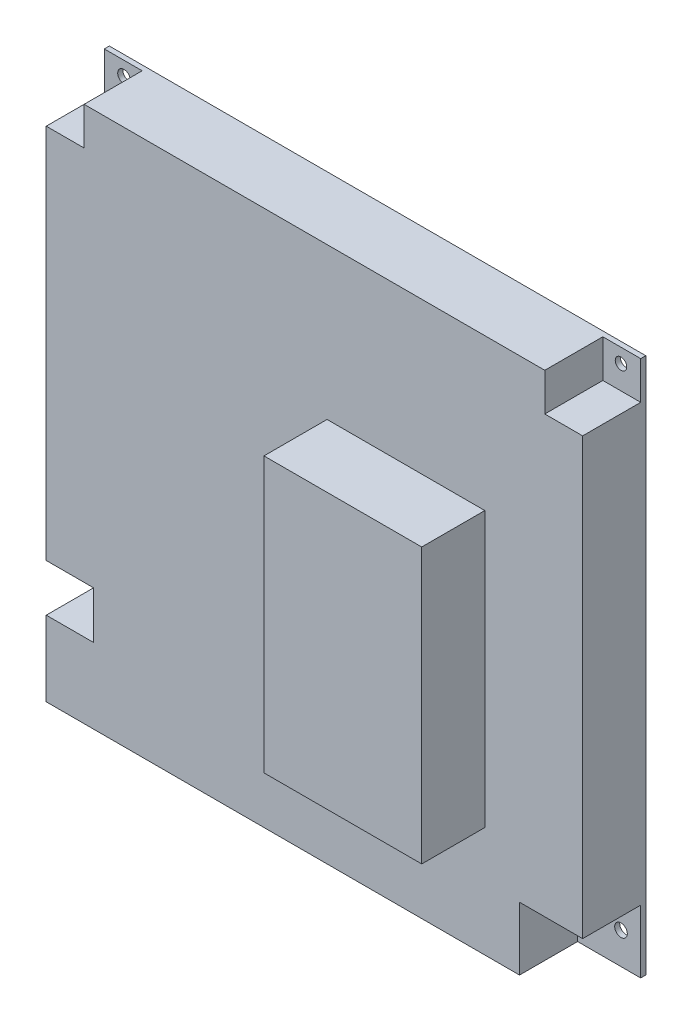
from build123d import *

# Parameters (mm, degrees)
SKETCH_1_W          = 170
SKETCH_1_H          = 170
EXTRUDE_1_DEPTH     = 20
SKETCH_2_W          = 20
SKETCH_2_H          = 20
SKETCH_2_W_2        = 12
SKETCH_2_H_2        = 12
SKETCH_2_W_3        = 15
SKETCH_2_H_3        = 15
CUT_EXTRUDE_1_DEPTH = 18.4
SKETCH_3_R          = 2
SKETCH_3_R_2        = 1.82271494
CUT_EXTRUDE_2_DEPTH = 18.4
SKETCH_4_W          = 50
SKETCH_4_H          = 87
EXTRUDE_2_DEPTH     = 20


with BuildPart() as part:
    # 草圖1 → 填料-伸長1 (new body)
    with BuildSketch(Plane.XY):
        Rectangle(SKETCH_1_W, SKETCH_1_H)
    extrude(amount=EXTRUDE_1_DEPTH)

    # 草圖2 → 除料-伸長1 (cut)
    with BuildSketch(Plane.XY.offset(20)):
        with Locations((75, -75)):
            Rectangle(SKETCH_2_W, SKETCH_2_H)
        with Locations((79, 79)):
            Rectangle(SKETCH_2_W_2, SKETCH_2_H_2)
        with Locations((-79, 79)):
            Rectangle(SKETCH_2_W_2, SKETCH_2_H_2)
        with Locations((-77.5, -53.711717692)):
            Rectangle(SKETCH_2_W_3, SKETCH_2_H_3)
    extrude(amount=-CUT_EXTRUDE_1_DEPTH, mode=Mode.SUBTRACT)

    # 草圖3 → 除料-伸長2 (cut)
    with BuildSketch(Plane.XY.offset(1.6)):
        with Locations((78.75, -75)):
            Circle(SKETCH_3_R)
        with Locations((78.75, 80.5)):
            Circle(SKETCH_3_R_2)
        with Locations((-78.75, 80.5)):
            Circle(SKETCH_3_R)
        with Locations((-78.75, -51.5)):
            Circle(SKETCH_3_R)
    extrude(amount=-CUT_EXTRUDE_2_DEPTH, mode=Mode.SUBTRACT)

    # 草圖4 → 填料-伸長2 (add)
    with BuildSketch(Plane.XY.offset(20)):
        with Locations((29, -6.5)):
            Rectangle(SKETCH_4_W, SKETCH_4_H)
    extrude(amount=EXTRUDE_2_DEPTH)


solid = part.part
